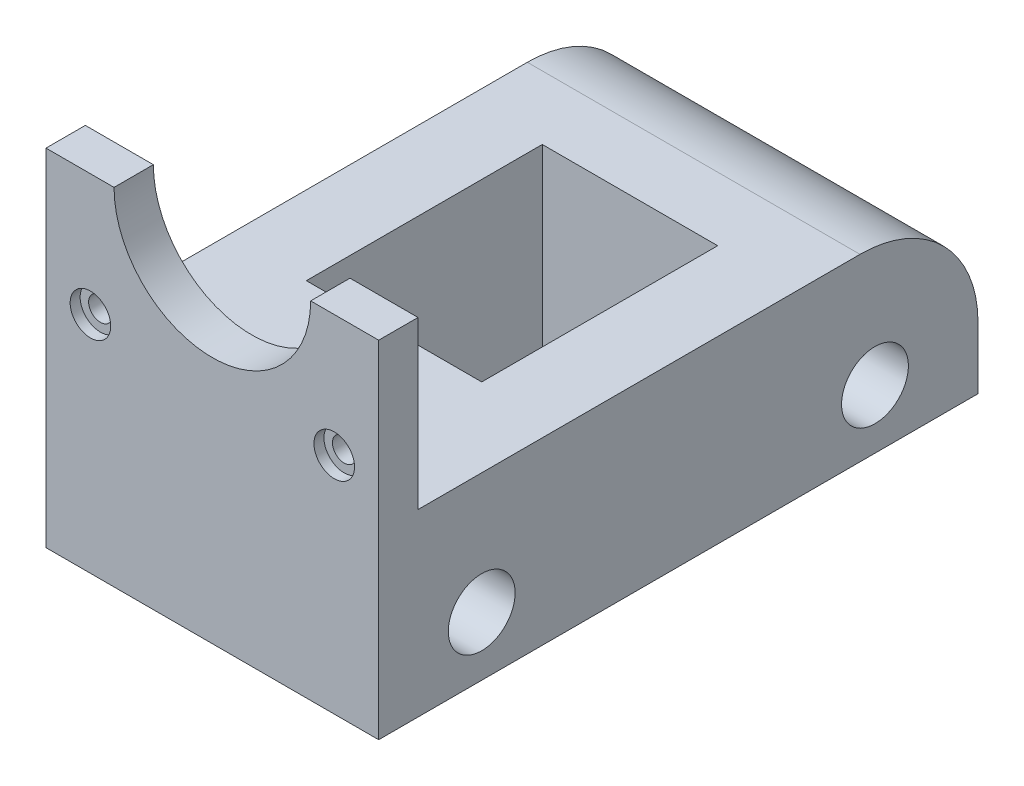
from build123d import *

# Parameters (mm, degrees)
SKETCH2_W                        = 42.3
SKETCH2_H                        = 76.2
BOSS_EXTRUDE1_DEPTH              = 15
SKETCH5_W                        = 42.3
SKETCH5_H                        = 42.3
MOUNTING_DEPTH                   = 5
SKETCH6_R                        = 12.5
SKETCH6_W                        = 42.3
SKETCH6_H                        = 21.15
PULLY_HOLE_DEPTH                 = 77.2
SKETCH8_R                        = 1.5
CUT_EXTRUDE_M3_DEPTH             = 77.2
SKETCH9_R                        = 2.58
SCREW_TOPS_DEPTH                 = 1.27
SKETCH11_W                       = 22.3
SKETCH11_H                       = 30
CUT_EXTRUDE1_DEPTH               = 37.15
SKETCH12_W                       = 42.3
SKETCH12_H                       = 76.2
SKETCH12_W_2                     = 22.3
SKETCH12_H_2                     = 30
F_7_85_CORRECTION_TO_MATCH_DEPTH = 7.85
SKETCH13_R                       = 4.25
CUT_EXTRUDE2_DEPTH               = 43.3
FILLET1_R                        = 15


with BuildPart() as part:
    # Sketch2 → Boss-Extrude1 (new body)
    with BuildSketch(Plane(origin=(0, 0, 0), x_dir=(1, 0, 0), z_dir=(0, 1, 0))):
        with Locations((1.968506494, -27.937012987)):
            Rectangle(SKETCH2_W, SKETCH2_H)
    extrude(amount=BOSS_EXTRUDE1_DEPTH)

    # Sketch5 → Mounting (add)
    with BuildSketch(Plane.XY.offset(66.037012987)):
        with Locations((1.968506494, 36.15)):
            Rectangle(SKETCH5_W, SKETCH5_H)
    extrude(amount=-MOUNTING_DEPTH)

    # Sketch6 → Pully Hole (cut, through all)
    with BuildSketch(Plane.XY.offset(66.037012987)):
        with Locations((1.968506494, 36.15)):
            Circle(SKETCH6_R)
        with Locations((1.968506494, 46.725)):
            Rectangle(SKETCH6_W, SKETCH6_H)
    extrude(amount=-PULLY_HOLE_DEPTH, mode=Mode.SUBTRACT)

    # Sketch8 → Cut-Extrude M3 (cut, through all)
    with BuildSketch(Plane.XY.offset(66.037012987)):
        with Locations((-13.531493506, 20.65)):
            Circle(SKETCH8_R)
        with Locations((17.468506494, 20.65)):
            Circle(SKETCH8_R)
    extrude(amount=-CUT_EXTRUDE_M3_DEPTH, mode=Mode.SUBTRACT)

    # Sketch9 → Screw Tops (cut)
    with BuildSketch(Plane.XY.offset(66.037012987)):
        with Locations((-13.531493506, 20.65)):
            Circle(SKETCH9_R)
        with Locations((17.468506494, 20.65)):
            Circle(SKETCH9_R)
    extrude(amount=-SCREW_TOPS_DEPTH, mode=Mode.SUBTRACT)

    # Sketch11 → Cut-Extrude1 (cut, through all)
    with BuildSketch(Plane.XZ):
        with Locations((1.968506494, 27.937012987)):
            Rectangle(SKETCH11_W, SKETCH11_H)
    extrude(amount=-CUT_EXTRUDE1_DEPTH, mode=Mode.SUBTRACT)

    # Sketch12 → 7.85 correction to match (add)
    with BuildSketch(Plane.XZ):
        with Locations((1.968506494, 27.937012987)):
            Rectangle(SKETCH12_W, SKETCH12_H)
        with Locations((1.968506494, 27.937012987)):
            Rectangle(SKETCH12_W_2, SKETCH12_H_2, mode=Mode.SUBTRACT)
    extrude(amount=F_7_85_CORRECTION_TO_MATCH_DEPTH)

    # Sketch13 → Cut-Extrude2 (cut, through all)
    with BuildSketch(Plane(origin=(23.118506494, 0, 0), x_dir=(0, 0, -1), z_dir=(1, 0, 0))):
        with Locations((-52.937012987, -0.35)):
            Circle(SKETCH13_R)
        with Locations((-2.937012987, -0.35)):
            Circle(SKETCH13_R)
    extrude(amount=-CUT_EXTRUDE2_DEPTH, mode=Mode.SUBTRACT)

    # Fillet1
    fillet1_edges = [part.edges().sort_by_distance(p)[0] for p in [
        (1.968506494, 15, -10.162987013),
    ]]
    fillet(fillet1_edges, radius=FILLET1_R)


solid = part.part
